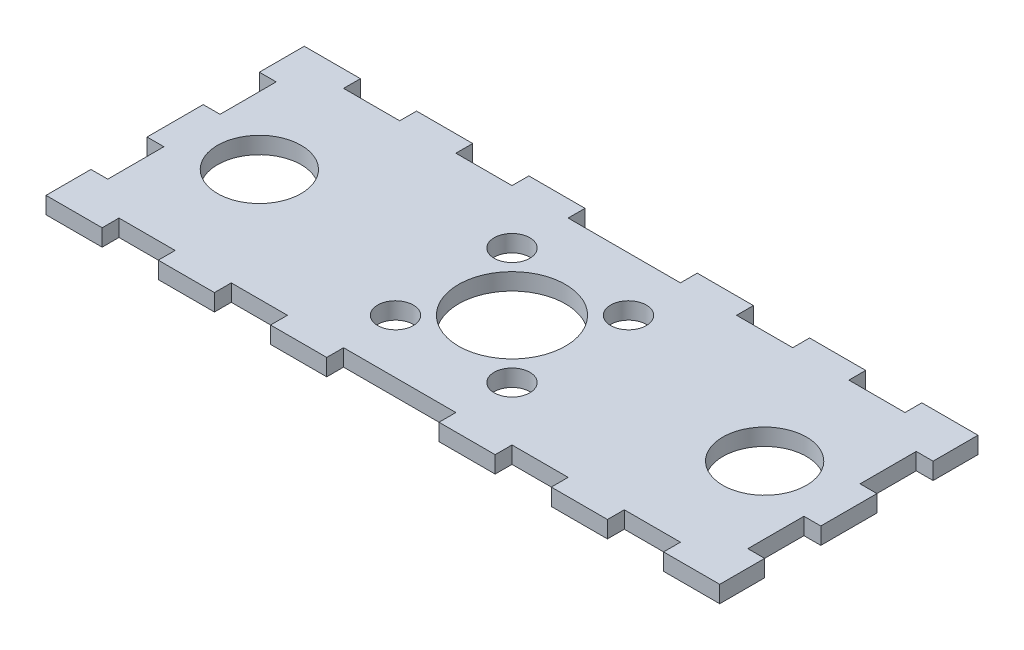
from build123d import *

# Parameters (mm, degrees)
SKETCH1_W           = 120
SKETCH1_H           = 40
BOSS_EXTRUDE1_DEPTH = 3
SKETCH2_R           = 7.45
SKETCH2_R_2         = 9.525
SKETCH2_R_3         = 3.175
CUT_EXTRUDE1_DEPTH  = 4
SKETCH4_W           = 10
SKETCH4_H           = 3
BOSS_EXTRUDE2_DEPTH = 3
SKETCH5_W           = 3
SKETCH5_H           = 10
CUT_EXTRUDE2_DEPTH  = 4


with BuildPart() as part:
    # Sketch1 → Boss-Extrude1 (new body)
    with BuildSketch(Plane(origin=(0, 0, 0), x_dir=(1, 0, 0), z_dir=(0, 1, 0))):
        Rectangle(SKETCH1_W, SKETCH1_H)
    extrude(amount=BOSS_EXTRUDE1_DEPTH)

    # Sketch2 → Cut-Extrude1 (cut, through all)
    with BuildSketch(Plane(origin=(0, 3, 0), x_dir=(1, 0, 0), z_dir=(0, 1, 0))):
        with Locations((45, 0)):
            Circle(SKETCH2_R)
        with Locations((-45, 0)):
            Circle(SKETCH2_R)
        Circle(SKETCH2_R_2)
        with Locations((10.375, 10.375)):
            Circle(SKETCH2_R_3)
        with Locations((10.375, -10.375)):
            Circle(SKETCH2_R_3)
        with Locations((-10.375, -10.375)):
            Circle(SKETCH2_R_3)
        with Locations((-10.375, 10.375)):
            Circle(SKETCH2_R_3)
    extrude(amount=-CUT_EXTRUDE1_DEPTH, mode=Mode.SUBTRACT)

    # Sketch4 → Boss-Extrude2 (add)
    with BuildSketch(Plane(origin=(0, 3, 0), x_dir=(1, 0, 0), z_dir=(0, 1, 0))):
        with Locations((15, 21.5)):
            Rectangle(SKETCH4_W, SKETCH4_H)
        with Locations((35, 21.5)):
            Rectangle(SKETCH4_W, SKETCH4_H)
        with Locations((55, 21.5)):
            Rectangle(SKETCH4_W, SKETCH4_H)
        with Locations((-55, 21.5)):
            Rectangle(SKETCH4_W, SKETCH4_H)
        with Locations((-35, 21.5)):
            Rectangle(SKETCH4_W, SKETCH4_H)
        with Locations((-15, 21.5)):
            Rectangle(SKETCH4_W, SKETCH4_H)
        with Locations((-15, -21.5)):
            Rectangle(SKETCH4_W, SKETCH4_H)
        with Locations((-35, -21.5)):
            Rectangle(SKETCH4_W, SKETCH4_H)
        with Locations((-55, -21.5)):
            Rectangle(SKETCH4_W, SKETCH4_H)
        with Locations((55, -21.5)):
            Rectangle(SKETCH4_W, SKETCH4_H)
        with Locations((35, -21.5)):
            Rectangle(SKETCH4_W, SKETCH4_H)
        with Locations((15, -21.5)):
            Rectangle(SKETCH4_W, SKETCH4_H)
    extrude(amount=-BOSS_EXTRUDE2_DEPTH)

    # Sketch5 → Cut-Extrude2 (cut, through all)
    with BuildSketch(Plane(origin=(0, 3, 0), x_dir=(1, 0, 0), z_dir=(0, 1, 0))):
        with Locations((58.5, 10)):
            Rectangle(SKETCH5_W, SKETCH5_H)
        with Locations((58.5, -10)):
            Rectangle(SKETCH5_W, SKETCH5_H)
    cut_extrude2 = extrude(amount=-CUT_EXTRUDE2_DEPTH, mode=Mode.SUBTRACT)

    # Mirror1: Cut-Extrude2 across plane
    add(cut_extrude2.mirror(Plane(origin=(0, 0, 0), x_dir=(0, 0, 1), z_dir=(1, 0, 0))), mode=Mode.SUBTRACT)


solid = part.part
